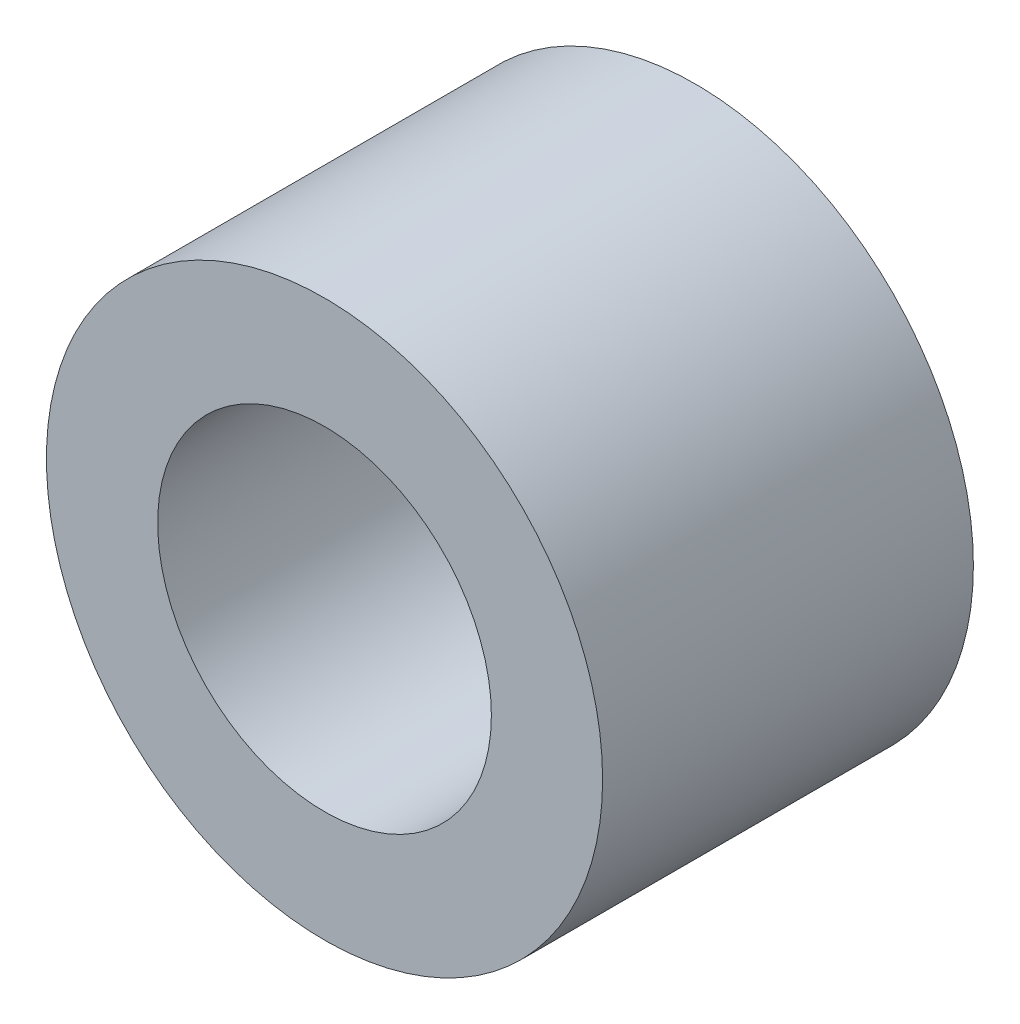
from build123d import *

# Parameters (mm, degrees)
SKETCH1_R      = 2.25
SKETCH1_R_2    = 1.35
EXTRUDE1_DEPTH = 1.5


with BuildPart() as part:
    # Sketch1 → Extrude1 (new body, symmetric)
    with BuildSketch(Plane.XY):
        Circle(SKETCH1_R)
        Circle(SKETCH1_R_2, mode=Mode.SUBTRACT)
    extrude(amount=EXTRUDE1_DEPTH, both=True)


solid = part.part
